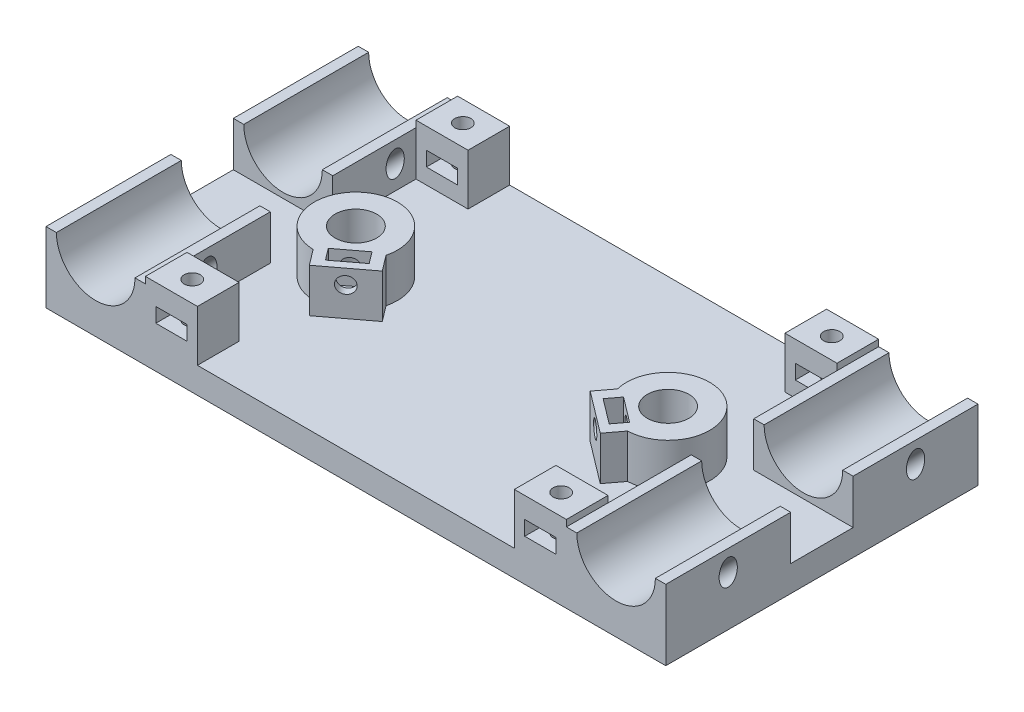
from build123d import *

# Parameters (mm, degrees)
SKETCH1_W                 = 119.1
SKETCH1_H                 = 60
BOSS_EXTRUDE1_DEPTH       = 5
BOSS_EXTRUDE2_DEPTH       = 24
MIRROR2_COPY_1_DEPTH      = 24
SKETCH3_R                 = 1.75
CUT_EXTRUDE1_DEPTH        = 102.850411143
MIRROR4_COPY_1_SKETCH_R   = 1.75
MIRROR4_COPY_1_DEPTH      = 102.850411143
MIRROR5_COPY_1_SKETCH_R   = 1.75
MIRROR5_COPY_1_DEPTH      = 102.850411143
MIRROR5_COPY_2_SKETCH_R   = 1.75
MIRROR5_COPY_2_DEPTH      = 102.850411143
MIRROR5_COPY_3_SKETCH_R   = 1.75
MIRROR5_COPY_3_DEPTH      = 102.850411143
SKETCH4_R                 = 8
SKETCH4_R_2               = 4
BOSS_EXTRUDE3_DEPTH       = 8.4
CUT_EXTRUDE3_DEPTH        = 6
SKETCH7_R                 = 1.561398203
CUT_EXTRUDE4_DEPTH        = 8
SKETCH8_R                 = 4
CUT_EXTRUDE5_DEPTH        = 8
SKETCH9_W                 = 10
SKETCH9_H                 = 9.8
SKETCH9_W_2               = 6
SKETCH9_H_2               = 2.8
BOSS_EXTRUDE4_DEPTH       = 8
MIRROR9_COPY_1_SKETCH_W   = 10
MIRROR9_COPY_1_SKETCH_H   = 9.8
MIRROR9_COPY_1_SKETCH_W_2 = 6
MIRROR9_COPY_1_SKETCH_H_2 = 2.8
MIRROR9_COPY_1_DEPTH      = 8
SKETCH10_R                = 1.55
CUT_EXTRUDE6_DEPTH        = 69.3025805


with BuildPart() as part:
    # Sketch1 → Boss-Extrude1 (new body)
    with BuildSketch(Plane(origin=(0, 0, 0), x_dir=(1, 0, 0), z_dir=(0, 1, 0))):
        Rectangle(SKETCH1_W, SKETCH1_H)
    extrude(amount=BOSS_EXTRUDE1_DEPTH)

    # Sketch2 → Boss-Extrude2 (add)
    with BuildSketch(Plane.XY.offset(30)):
        with BuildLine():
            Line((-59.55, 13.55), (-59.55, 5))
            Line((-59.55, 5), (-40.45, 5))
            Line((-40.45, 5), (-40.45, 13.55))
            Line((-40.45, 13.55), (-42.45, 13.55))
            ThreePointArc((-42.45, 13.55), (-50, 6), (-57.55, 13.55))
            Line((-57.55, 13.55), (-59.55, 13.55))
        make_face()
    boss_extrude2 = extrude(amount=-BOSS_EXTRUDE2_DEPTH)

    # Mirror1: Boss-Extrude2 across plane
    add(boss_extrude2.mirror(Plane.XY))

    # Mirror2: Boss-Extrude2 across plane
    add(boss_extrude2.mirror(Plane(origin=(0, 0, 0), x_dir=(0, 0, 1), z_dir=(1, 0, 0))))

    # Mirror2 copy 1 sketch → Mirror2 copy 1 (add)
    with BuildSketch(Plane(origin=(0, 0, -30), x_dir=(-1, 0, 0), z_dir=(0, 0, -1))):
        with BuildLine():
            Line((-59.55, 13.55), (-59.55, 5))
            Line((-59.55, 5), (-40.45, 5))
            Line((-40.45, 5), (-40.45, 13.55))
            Line((-40.45, 13.55), (-42.45, 13.55))
            ThreePointArc((-42.45, 13.55), (-50, 6), (-57.55, 13.55))
            Line((-57.55, 13.55), (-59.55, 13.55))
        make_face()
    extrude(amount=-MIRROR2_COPY_1_DEPTH)

    # Sketch3 → Cut-Extrude1 (cut, symmetric)
    with BuildSketch(Plane(origin=(-32.275, 32.275, 0), x_dir=(0.7071067811865477, 0.7071067811865475, 0), z_dir=(-0.7071067811865475, 0.7071067811865477, 0))):
        with Locations(Location((-35.355339059, -18, 0), (0, 0, 180))):
            Circle(SKETCH3_R)
    cut_extrude1 = extrude(amount=CUT_EXTRUDE1_DEPTH, both=True, mode=Mode.SUBTRACT)

    # Mirror3: Cut-Extrude1 across plane
    add(cut_extrude1.mirror(Plane.ZY.offset(50)), mode=Mode.SUBTRACT)

    # Mirror4: Cut-Extrude1 across plane
    add(cut_extrude1.mirror(Plane.XY), mode=Mode.SUBTRACT)

    # Mirror4 copy 1 sketch → Mirror4 copy 1 (cut, symmetric)
    with BuildSketch(Plane(origin=(-67.725, 32.275, 0), x_dir=(-0.7071067811865477, 0.7071067811865475, 0), z_dir=(0.7071067811865475, 0.7071067811865477, 0))):
        with Locations(Location((-35.355339059, -18, 0), (0, 0, 180))):
            Circle(MIRROR4_COPY_1_SKETCH_R)
    extrude(amount=MIRROR4_COPY_1_DEPTH, both=True, mode=Mode.SUBTRACT)

    # Mirror5: Cut-Extrude1 across plane
    add(cut_extrude1.mirror(Plane(origin=(0, 0, 0), x_dir=(0, 0, 1), z_dir=(1, 0, 0))), mode=Mode.SUBTRACT)

    # Mirror5 copy 1 sketch → Mirror5 copy 1 (cut, symmetric)
    with BuildSketch(Plane(origin=(67.725, 32.275, 0), x_dir=(0.7071067811865477, 0.7071067811865475, 0), z_dir=(-0.7071067811865475, 0.7071067811865477, 0))):
        with Locations(Location((-35.355339059, -18, 0), (0, 0, 180))):
            Circle(MIRROR5_COPY_1_SKETCH_R)
    extrude(amount=MIRROR5_COPY_1_DEPTH, both=True, mode=Mode.SUBTRACT)

    # Mirror5 copy 2 sketch → Mirror5 copy 2 (cut, symmetric)
    with BuildSketch(Plane(origin=(32.275, 32.275, 0), x_dir=(-0.7071067811865477, 0.7071067811865475, 0), z_dir=(0.7071067811865475, 0.7071067811865477, 0))):
        with Locations(Location((-35.355339059, -18, 0), (0, 0, 180))):
            Circle(MIRROR5_COPY_2_SKETCH_R)
    extrude(amount=MIRROR5_COPY_2_DEPTH, both=True, mode=Mode.SUBTRACT)

    # Mirror5 copy 3 sketch → Mirror5 copy 3 (cut, symmetric)
    with BuildSketch(Plane(origin=(67.725, 32.275, 0), x_dir=(0.7071067811865477, 0.7071067811865475, 0), z_dir=(-0.7071067811865475, 0.7071067811865477, 0))):
        with Locations((-35.355339059, 18)):
            Circle(MIRROR5_COPY_3_SKETCH_R)
    extrude(amount=MIRROR5_COPY_3_DEPTH, both=True, mode=Mode.SUBTRACT)

    # Sketch4 → Boss-Extrude3 (add)
    with BuildSketch(Plane(origin=(0, 5, 0), x_dir=(1, 0, 0), z_dir=(0, 1, 0))):
        with Locations((-30, 0)):
            Circle(SKETCH4_R)
        with Locations(Location((-30, 0, 0), (0, 0, 270))):
            Circle(SKETCH4_R_2, mode=Mode.SUBTRACT)
        with BuildLine():
            Line((-30.217325584, -7.997047555), (-27.950944845, -10.99096779))
            Line((-27.950944845, -10.99096779), (-19.977792674, -4.95533655))
            Line((-19.977792674, -4.95533655), (-22.244173413, -1.961416314))
            ThreePointArc((-22.244173413, -1.961416314), (-25.171495008, -6.378521736), (-30.217325584, -7.997047555))
        make_face()
    boss_extrude3 = extrude(amount=BOSS_EXTRUDE3_DEPTH)

    # Sketch6 → Cut-Extrude3 (cut)
    with BuildSketch(Plane(origin=(0, 13.4, 0), x_dir=(1, 0, 0), z_dir=(0, 1, 0))):
        Polygon((-28.951635844, -6.355386109), (-24.167744542, -2.734007365), (-22.477767795, -4.966489973), (-27.261659097, -8.587868717), align=None)
    cut_extrude3 = extrude(amount=-CUT_EXTRUDE3_DEPTH, mode=Mode.SUBTRACT)

    # Sketch7 → Cut-Extrude4 (cut)
    with BuildSketch(Plane(origin=(-4.893022101, 0, -6.463749727), x_dir=(0.797315217025082, 0, -0.6035631240394382), z_dir=(0.6035631240394382, 0, 0.797315217025082))):
        with Locations((-23.919456511, 10.6)):
            Circle(SKETCH7_R)
    cut_extrude4 = extrude(amount=-CUT_EXTRUDE4_DEPTH, mode=Mode.SUBTRACT)

    # Mirror7: Boss-Extrude3, Cut-Extrude3, Cut-Extrude4 across plane
    add(boss_extrude3.mirror(Plane(origin=(0, 0, 0), x_dir=(0, 0, 1), z_dir=(1, 0, 0))))
    add(cut_extrude3.mirror(Plane(origin=(0, 0, 0), x_dir=(0, 0, 1), z_dir=(1, 0, 0))), mode=Mode.SUBTRACT)
    add(cut_extrude4.mirror(Plane(origin=(0, 0, 0), x_dir=(0, 0, 1), z_dir=(1, 0, 0))), mode=Mode.SUBTRACT)

    # Sketch8 → Cut-Extrude5 (cut)
    with BuildSketch(Plane(origin=(0, 5, 0), x_dir=(1, 0, 0), z_dir=(0, 1, 0))):
        with Locations(Location((-30, 0, 0), (0, 0, 270))):
            Circle(SKETCH8_R)
        with Locations(Location((30, 0, 0), (0, 0, 270))):
            Circle(SKETCH8_R)
    extrude(amount=-CUT_EXTRUDE5_DEPTH, mode=Mode.SUBTRACT)

    # Sketch9 → Boss-Extrude4 (add)
    with BuildSketch(Plane.XY.offset(30)):
        with Locations((-35.45, 9.9)):
            Rectangle(SKETCH9_W, SKETCH9_H)
        with Locations((-35.45, 9.4)):
            Rectangle(SKETCH9_W_2, SKETCH9_H_2, mode=Mode.SUBTRACT)
    boss_extrude4 = extrude(amount=-BOSS_EXTRUDE4_DEPTH)

    # Mirror8: Boss-Extrude4 across plane
    add(boss_extrude4.mirror(Plane(origin=(0, 0, 0), x_dir=(0, 0, 1), z_dir=(1, 0, 0))))

    # Mirror9: Boss-Extrude4 across plane
    add(boss_extrude4.mirror(Plane.XY))

    # Mirror9 copy 1 sketch → Mirror9 copy 1 (add)
    with BuildSketch(Plane(origin=(0, 0, -30), x_dir=(-1, 0, 0), z_dir=(0, 0, -1))):
        with Locations((-35.45, 9.9)):
            Rectangle(MIRROR9_COPY_1_SKETCH_W, MIRROR9_COPY_1_SKETCH_H)
        with Locations((-35.45, 9.4)):
            Rectangle(MIRROR9_COPY_1_SKETCH_W_2, MIRROR9_COPY_1_SKETCH_H_2, mode=Mode.SUBTRACT)
    extrude(amount=-MIRROR9_COPY_1_DEPTH)

    # Sketch10 → Cut-Extrude6 (cut, through all)
    with BuildSketch(Plane(origin=(0, 14.8, 0), x_dir=(1, 0, 0), z_dir=(0, 1, 0))):
        with Locations(Location((-35.45, 26, 0), (0, 0, 270))):
            Circle(SKETCH10_R)
        with Locations(Location((35.45, 26, 0), (0, 0, 270))):
            Circle(SKETCH10_R)
        with Locations(Location((35.45, -26, 0), (0, 0, 270))):
            Circle(SKETCH10_R)
        with Locations(Location((-35.45, -26, 0), (0, 0, 270))):
            Circle(SKETCH10_R)
    extrude(amount=-CUT_EXTRUDE6_DEPTH, mode=Mode.SUBTRACT)


solid = part.part
